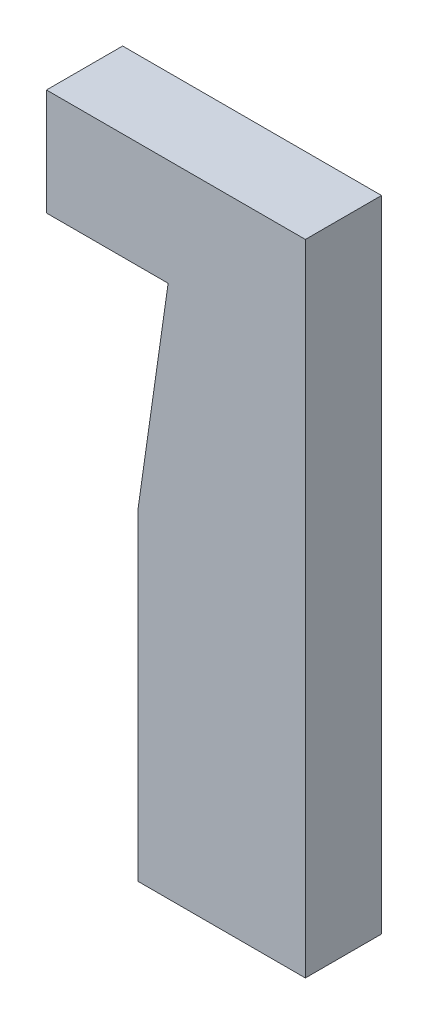
from build123d import *

# Parameters (mm, degrees)
SKETCH2_W           = 7.62
SKETCH2_H           = 8.89
SKETCH2_W_2         = 13.97
SKETCH2_H_2         = 44.45
BOSS_EXTRUDE1_DEPTH = 6.35
SKETCH3_R           = 4.0005
CUT_EXTRUDE1_DEPTH  = 2.794
CUT_EXTRUDE2_DEPTH  = 1.5875
CUT_EXTRUDE3_DEPTH  = 7.35


with BuildPart() as part:
    # Sketch2 → Boss-Extrude1 (new body)
    with BuildSketch(Plane.XY):
        with Locations((-17.78, 48.895)):
            Rectangle(SKETCH2_W, SKETCH2_H)
        with Locations((-6.985, 48.895)):
            Rectangle(SKETCH2_W_2, SKETCH2_H)
        with Locations((-6.985, 22.225)):
            Rectangle(SKETCH2_W_2, SKETCH2_H_2)
    extrude(amount=BOSS_EXTRUDE1_DEPTH)

    # Sketch3 → Cut-Extrude1 (cut)
    with BuildSketch(Plane(origin=(0, 0, 0), x_dir=(-1, 0, 0), z_dir=(0, 0, -1))):
        with Locations((6.985, 15.24)):
            Circle(SKETCH3_R)
    extrude(amount=-CUT_EXTRUDE1_DEPTH, mode=Mode.SUBTRACT)

    # Sketch4 → Cut-Extrude2 (cut)
    with BuildSketch(Plane(origin=(0, 0, 0), x_dir=(-1, 0, 0), z_dir=(0, 0, -1))):
        Polygon((6.985, 29.718), (9.017, 29.718), (9.017, 15.24), (9.017, 0.762), (4.953, 0.762), (4.953, 15.24), (4.953, 29.718), align=None)
    extrude(amount=-CUT_EXTRUDE2_DEPTH, mode=Mode.SUBTRACT)

    # Sketch5 → Cut-Extrude3 (cut, through all)
    with BuildSketch(Plane(origin=(0, 0, 0), x_dir=(-1, 0, 0), z_dir=(0, 0, -1))):
        Polygon((13.97, 44.45), (11.44430778, 44.45), (13.97, 26.791745209), align=None)
    extrude(amount=-CUT_EXTRUDE3_DEPTH, mode=Mode.SUBTRACT)


solid = part.part
